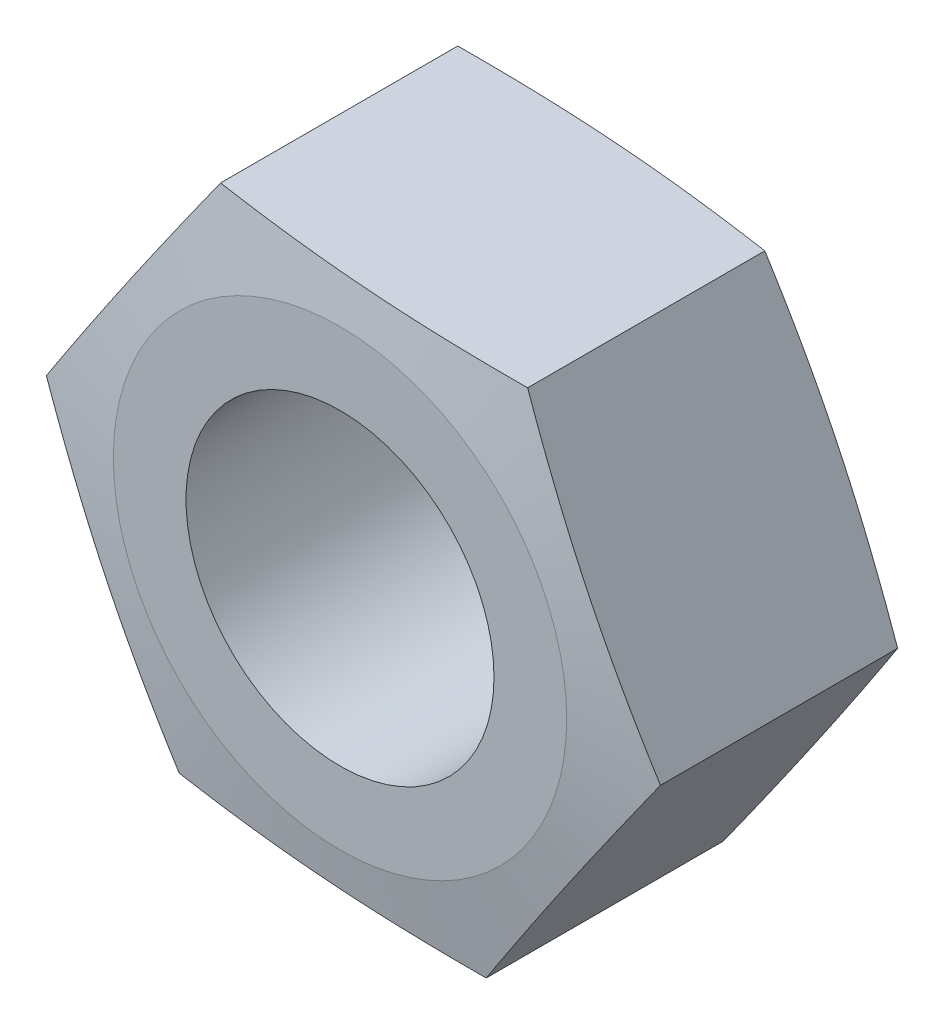
from build123d import *

# Parameters (mm, degrees)
EXTRUDE_1_DEPTH     = 6
SKETCH_5_R          = 3.5
CUT_EXTRUDE_2_DEPTH = 7
CHAMFER_1_SIZE      = 0.5


with BuildPart() as part:
    # Эскиз1 → Вытянуть1 (new body)
    with BuildSketch(Plane.XY):
        Polygon((-3.019213701, 6.315405658), (-6.978908586, 0.542987065), (-3.959694885, -5.772418593), (3.019213701, -6.315405658), (6.978908586, -0.542987065), (3.959694885, 5.772418593), align=None)
    extrude(amount=EXTRUDE_1_DEPTH)

    # Вырез-По траектории1: sweep along a path in Эскиз3
    with BuildLine(Plane(origin=(0, 0, 0), x_dir=(-1, 0, 0), z_dir=(0, 0, -1))) as sweep_1_path:
        CenterArc((0, 0), 4.80754516, 0, 360)
    # Эскиз4 → Вырез-По траектории1 (sweep, cut)
    with BuildSketch(Plane(origin=(0, 0, 0), x_dir=(1, 0, 0), z_dir=(0, 1, 0))):
        Polygon((-5.152045548, 0), (-8.017144415, -0.472678529), (-8.017144415, 0.689853389), align=None)
    sweep_1 = sweep(path=sweep_1_path.line, mode=Mode.SUBTRACT)

    # Зеркальное отражение1: Вырез-По траектории1 across plane
    add(sweep_1.mirror(Plane(origin=(0, 0, 3), x_dir=(1, 0, 0), z_dir=(0, 0, -1))), mode=Mode.SUBTRACT)

    # Эскиз5 → Вытянуть2 (cut, through all)
    with BuildSketch(Plane.XY.offset(6)):
        Circle(SKETCH_5_R)
    extrude(amount=-CUT_EXTRUDE_2_DEPTH, mode=Mode.SUBTRACT)

    # Фаска1
    chamfer_1_edges = [part.edges().sort_by_distance(p)[0] for p in [
        (-3.5, 0, 0),
    ]]
    chamfer(chamfer_1_edges, length=CHAMFER_1_SIZE)


solid = part.part
